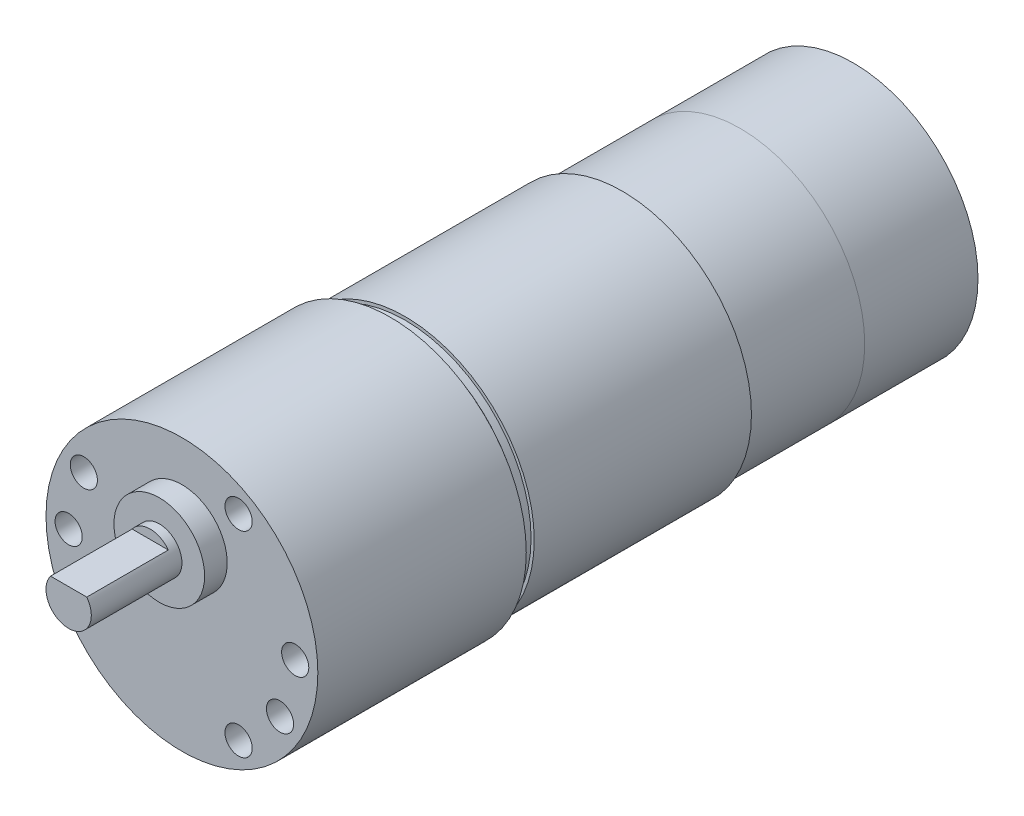
from build123d import *

# Parameters (mm, degrees)
SKETCH_3_R          = 13.75
EXTRUDE_1_DEPTH     = 12.5
SKETCH_4_R          = 1.5
CUT_EXTRUDE_1_DEPTH = 4
SKETCH_5_R          = 5
EXTRUDE_2_DEPTH     = 2.5
SKETCH_6_R          = 2.5
EXTRUDE_3_DEPTH     = 10
CUT_EXTRUDE_2_DEPTH = 9


with BuildPart() as part:
    # Эскиз2 → Повернуть1 (revolve)
    with BuildSketch(Plane(origin=(0, 0, 0), x_dir=(0, 0, -1), z_dir=(1, 0, 0))):
        Polygon((0, 0), (0, 15), (23, 15), (23, 13.160869224), (23.8, 13.160869224), (23.8, 13.900188548), (24.629157433, 13.900188548), (24.629157433, 14.25), (48.6, 14.25), (48.6, 13.75), (61.6, 13.75), (61.6, 0), align=None)
    revolve(axis=Axis((0, 0, 0), (0, 0, -1)))

    # Эскиз4 → Вырез-Вытянуть1 (cut)
    with BuildSketch(Plane.XY):
        with Locations((-12.5, 0)):
            Circle(SKETCH_4_R)
        with Locations((-10.825317547, 6.25)):
            Circle(SKETCH_4_R)
        with Locations((6.25, 10.825317547)):
            Circle(SKETCH_4_R)
        with Locations((12.5, 0)):
            Circle(SKETCH_4_R)
        with Locations((10.825317547, -6.25)):
            Circle(SKETCH_4_R)
        with Locations((6.25, -10.825317547)):
            Circle(SKETCH_4_R)
    extrude(amount=-CUT_EXTRUDE_1_DEPTH, mode=Mode.SUBTRACT)

    # Эскиз5 → Бобышка-Вытянуть2 (add)
    with BuildSketch(Plane.XY):
        with Locations((0, 5.5)):
            Circle(SKETCH_5_R)
    extrude(amount=EXTRUDE_2_DEPTH)

    # Эскиз6 → Бобышка-Вытянуть3 (add)
    with BuildSketch(Plane.XY.offset(2.5)):
        with Locations((0, 5.5)):
            Circle(SKETCH_6_R)
    extrude(amount=EXTRUDE_3_DEPTH)

    # Эскиз7 → Вырез-Вытянуть2 (cut)
    with BuildSketch(Plane.XY.offset(12.5)):
        Polygon((-2.640466968, 7), (2.828249594, 7), (2.828249594, 8.822905521), (-1.513579919, 8.822905521), align=None)
    extrude(amount=-CUT_EXTRUDE_2_DEPTH, mode=Mode.SUBTRACT)


with BuildPart() as body_2:
    # Эскиз3 → Бобышка-Вытянуть1 (new body)
    with BuildSketch(Plane(origin=(0, 0, -61.6), x_dir=(-1, 0, 0), z_dir=(0, 0, -1))):
        Circle(SKETCH_3_R)
    extrude(amount=EXTRUDE_1_DEPTH)


solid = Compound([part.part, body_2.part])
